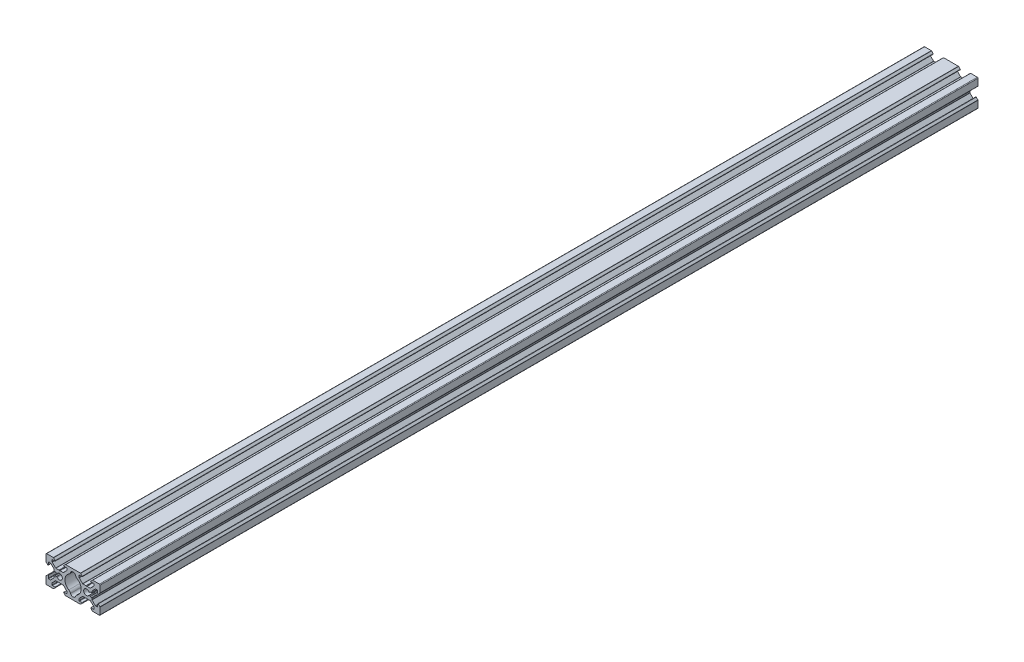
from build123d import *

# Parameters (mm, degrees)
BOSS_EXTRUDE1_DEPTH = 650


with BuildPart() as part:
    # Model → Boss-Extrude1 (new body)
    with BuildSketch(Plane.XY):
        with BuildLine():
            Line((2260.91910134, 1499.253690176), (2259.598426375, 1499.253690176))
            ThreePointArc((2259.598426375, 1499.253690176), (2259.42164968, 1499.180466871), (2259.348426375, 1499.003690176))
            Line((2259.348426375, 1499.003690176), (2259.348426375, 1497.153690176))
            ThreePointArc((2259.348426375, 1497.153690176), (2259.194097233, 1496.922720293), (2258.92164968, 1496.97691348))
            Line((2258.92164968, 1496.97691348), (2257.736294341, 1498.16226882))
            ThreePointArc((2257.736294341, 1498.16226882), (2257.671262515, 1498.259595824), (2257.648426375, 1498.374400854))
            Line((2257.648426375, 1498.374400854), (2257.648426375, 1503.303690176))
            ThreePointArc((2257.648426375, 1503.303690176), (2257.794872984, 1503.657243566), (2258.148426375, 1503.803690176))
            Line((2258.148426375, 1503.803690176), (2263.077715697, 1503.803690176))
            ThreePointArc((2263.077715697, 1503.803690176), (2263.192520727, 1503.780854036), (2263.289847731, 1503.71582221))
            Line((2263.289847731, 1503.71582221), (2264.47520307, 1502.530466871))
            ThreePointArc((2264.47520307, 1502.530466871), (2264.529396258, 1502.258019318), (2264.298426375, 1502.103690176))
            Line((2264.298426375, 1502.103690176), (2262.448426375, 1502.103690176))
            ThreePointArc((2262.448426375, 1502.103690176), (2262.27164968, 1502.030466871), (2262.198426375, 1501.853690176))
            Line((2262.198426375, 1501.853690176), (2262.198426375, 1500.533015211))
            ThreePointArc((2262.198426375, 1500.533015211), (2262.217456492, 1500.437344353), (2262.27164968, 1500.356238516))
            Line((2262.27164968, 1500.356238516), (2264.750974715, 1497.87691348))
            ThreePointArc((2264.750974715, 1497.87691348), (2264.832080552, 1497.822720293), (2264.92775141, 1497.803690176))
            Line((2264.92775141, 1497.803690176), (2267.187449152, 1497.803690176))
            ThreePointArc((2267.187449152, 1497.803690176), (2267.33046854, 1497.767404898), (2267.438891274, 1497.667326539))
            ThreePointArc((2267.438891274, 1497.667326539), (2267.648426375, 1497.553690176), (2267.857961476, 1497.667326539))
            ThreePointArc((2267.857961476, 1497.667326539), (2267.96638421, 1497.767404898), (2268.109403598, 1497.803690176))
            Line((2268.109403598, 1497.803690176), (2270.36910134, 1497.803690176))
            ThreePointArc((2270.36910134, 1497.803690176), (2270.464772198, 1497.822720293), (2270.545878035, 1497.87691348))
            Line((2270.545878035, 1497.87691348), (2273.02520307, 1500.356238516))
            ThreePointArc((2273.02520307, 1500.356238516), (2273.079396258, 1500.437344353), (2273.098426375, 1500.533015211))
            Line((2273.098426375, 1500.533015211), (2273.098426375, 1501.853690176))
            ThreePointArc((2273.098426375, 1501.853690176), (2273.02520307, 1502.030466871), (2272.848426375, 1502.103690176))
            Line((2272.848426375, 1502.103690176), (2270.998426375, 1502.103690176))
            ThreePointArc((2270.998426375, 1502.103690176), (2270.767456492, 1502.258019318), (2270.82164968, 1502.530466871))
            Line((2270.82164968, 1502.530466871), (2272.007005019, 1503.71582221))
            ThreePointArc((2272.007005019, 1503.71582221), (2272.104332024, 1503.780854036), (2272.219137053, 1503.803690176))
            Line((2272.219137053, 1503.803690176), (2283.077715697, 1503.803690176))
            ThreePointArc((2283.077715697, 1503.803690176), (2283.192520727, 1503.780854036), (2283.289847731, 1503.71582221))
            Line((2283.289847731, 1503.71582221), (2284.47520307, 1502.530466871))
            ThreePointArc((2284.47520307, 1502.530466871), (2284.529396258, 1502.258019318), (2284.298426375, 1502.103690176))
            Line((2284.298426375, 1502.103690176), (2282.448426375, 1502.103690176))
            ThreePointArc((2282.448426375, 1502.103690176), (2282.27164968, 1502.030466871), (2282.198426375, 1501.853690176))
            Line((2282.198426375, 1501.853690176), (2282.198426375, 1500.533015211))
            ThreePointArc((2282.198426375, 1500.533015211), (2282.217456492, 1500.437344353), (2282.27164968, 1500.356238516))
            Line((2282.27164968, 1500.356238516), (2284.750974715, 1497.87691348))
            ThreePointArc((2284.750974715, 1497.87691348), (2284.832080552, 1497.822720293), (2284.92775141, 1497.803690176))
            Line((2284.92775141, 1497.803690176), (2287.187449152, 1497.803690176))
            ThreePointArc((2287.187449152, 1497.803690176), (2287.33046854, 1497.767404898), (2287.438891274, 1497.667326539))
            ThreePointArc((2287.438891274, 1497.667326539), (2287.648426375, 1497.553690176), (2287.857961476, 1497.667326539))
            ThreePointArc((2287.857961476, 1497.667326539), (2287.96638421, 1497.767404898), (2288.109403598, 1497.803690176))
            Line((2288.109403598, 1497.803690176), (2290.36910134, 1497.803690176))
            ThreePointArc((2290.36910134, 1497.803690176), (2290.464772198, 1497.822720293), (2290.545878035, 1497.87691348))
            Line((2290.545878035, 1497.87691348), (2293.02520307, 1500.356238516))
            ThreePointArc((2293.02520307, 1500.356238516), (2293.079396258, 1500.437344353), (2293.098426375, 1500.533015211))
            Line((2293.098426375, 1500.533015211), (2293.098426375, 1501.853690176))
            ThreePointArc((2293.098426375, 1501.853690176), (2293.02520307, 1502.030466871), (2292.848426375, 1502.103690176))
            Line((2292.848426375, 1502.103690176), (2290.998426375, 1502.103690176))
            ThreePointArc((2290.998426375, 1502.103690176), (2290.767456492, 1502.258019318), (2290.82164968, 1502.530466871))
            Line((2290.82164968, 1502.530466871), (2292.007005019, 1503.71582221))
            ThreePointArc((2292.007005019, 1503.71582221), (2292.104332023, 1503.780854036), (2292.219137053, 1503.803690176))
            Line((2292.219137053, 1503.803690176), (2297.148426375, 1503.803690176))
            ThreePointArc((2297.148426375, 1503.803690176), (2297.501979766, 1503.657243566), (2297.648426375, 1503.303690176))
            Line((2297.648426375, 1503.303690176), (2297.648426375, 1498.374400854))
            ThreePointArc((2297.648426375, 1498.374400854), (2297.625590235, 1498.259595824), (2297.560558409, 1498.16226882))
            Line((2297.560558409, 1498.16226882), (2296.37520307, 1496.97691348))
            ThreePointArc((2296.37520307, 1496.97691348), (2296.102755517, 1496.922720293), (2295.948426375, 1497.153690176))
            Line((2295.948426375, 1497.153690176), (2295.948426375, 1499.003690176))
            ThreePointArc((2295.948426375, 1499.003690176), (2295.87520307, 1499.180466871), (2295.698426375, 1499.253690176))
            Line((2295.698426375, 1499.253690176), (2294.37775141, 1499.253690176))
            ThreePointArc((2294.37775141, 1499.253690176), (2294.282080552, 1499.234660059), (2294.200974715, 1499.180466871))
            Line((2294.200974715, 1499.180466871), (2291.736294341, 1496.715786497))
            ThreePointArc((2291.736294341, 1496.715786497), (2291.671262515, 1496.618459492), (2291.648426375, 1496.503654462))
            Line((2291.648426375, 1496.503654462), (2291.648426375, 1495.603690176))
            ThreePointArc((2291.648426375, 1495.603690176), (2291.560558409, 1495.391558141), (2291.348426375, 1495.303690176))
            Line((2291.348426375, 1495.303690176), (2290.448462088, 1495.303690176))
            ThreePointArc((2290.448462088, 1495.303690176), (2290.333657059, 1495.280854035), (2290.236330054, 1495.21582221))
            Line((2290.236330054, 1495.21582221), (2289.891246967, 1494.870739123))
            ThreePointArc((2289.891246967, 1494.870739123), (2289.645694653, 1494.784738494), (2289.425278863, 1494.922973534))
            ThreePointArc((2289.425278863, 1494.922973534), (2285.548426375, 1493.803690176), (2289.425278863, 1492.684406817))
            ThreePointArc((2289.425278863, 1492.684406817), (2289.645694653, 1492.822641858), (2289.891246967, 1492.736641229))
            Line((2289.891246967, 1492.736641229), (2290.236330054, 1492.391558141))
            ThreePointArc((2290.236330054, 1492.391558141), (2290.333657059, 1492.326526316), (2290.448462089, 1492.303690176))
            Line((2290.448462089, 1492.303690176), (2291.348426375, 1492.303690176))
            ThreePointArc((2291.348426375, 1492.303690176), (2291.560558409, 1492.21582221), (2291.648426375, 1492.003690176))
            Line((2291.648426375, 1492.003690176), (2291.648426375, 1491.103725889))
            ThreePointArc((2291.648426375, 1491.103725889), (2291.671262515, 1490.988920859), (2291.736294341, 1490.891593855))
            Line((2291.736294341, 1490.891593855), (2294.200974715, 1488.42691348))
            ThreePointArc((2294.200974715, 1488.42691348), (2294.282080552, 1488.372720293), (2294.37775141, 1488.353690176))
            Line((2294.37775141, 1488.353690176), (2295.698426375, 1488.353690176))
            ThreePointArc((2295.698426375, 1488.353690176), (2295.87520307, 1488.42691348), (2295.948426375, 1488.603690176))
            Line((2295.948426375, 1488.603690176), (2295.948426375, 1490.453690176))
            ThreePointArc((2295.948426375, 1490.453690176), (2296.102755517, 1490.684660059), (2296.37520307, 1490.630466871))
            Line((2296.37520307, 1490.630466871), (2297.560558409, 1489.445111532))
            ThreePointArc((2297.560558409, 1489.445111532), (2297.625590235, 1489.347784527), (2297.648426375, 1489.232979498))
            Line((2297.648426375, 1489.232979498), (2297.648426375, 1484.303690176))
            ThreePointArc((2297.648426375, 1484.303690176), (2297.501979766, 1483.950136785), (2297.148426375, 1483.803690176))
            Line((2297.148426375, 1483.803690176), (2292.219137053, 1483.803690176))
            ThreePointArc((2292.219137053, 1483.803690176), (2292.104332023, 1483.826526316), (2292.007005019, 1483.891558141))
            Line((2292.007005019, 1483.891558141), (2290.82164968, 1485.07691348))
            ThreePointArc((2290.82164968, 1485.07691348), (2290.767456492, 1485.349361034), (2290.998426375, 1485.503690176))
            Line((2290.998426375, 1485.503690176), (2292.848426375, 1485.503690176))
            ThreePointArc((2292.848426375, 1485.503690176), (2293.02520307, 1485.57691348), (2293.098426375, 1485.753690176))
            Line((2293.098426375, 1485.753690176), (2293.098426375, 1487.07436514))
            ThreePointArc((2293.098426375, 1487.07436514), (2293.079396258, 1487.170035999), (2293.02520307, 1487.251141836))
            Line((2293.02520307, 1487.251141836), (2290.545878035, 1489.730466871))
            ThreePointArc((2290.545878035, 1489.730466871), (2290.464772198, 1489.784660059), (2290.36910134, 1489.803690176))
            Line((2290.36910134, 1489.803690176), (2288.109403598, 1489.803690176))
            ThreePointArc((2288.109403598, 1489.803690176), (2287.96638421, 1489.839975454), (2287.857961477, 1489.940053812))
            ThreePointArc((2287.857961477, 1489.940053812), (2287.648426375, 1490.053690176), (2287.438891274, 1489.940053812))
            ThreePointArc((2287.438891274, 1489.940053812), (2287.33046854, 1489.839975454), (2287.187449152, 1489.803690176))
            Line((2287.187449152, 1489.803690176), (2284.92775141, 1489.803690176))
            ThreePointArc((2284.92775141, 1489.803690176), (2284.832080552, 1489.784660059), (2284.750974715, 1489.730466871))
            Line((2284.750974715, 1489.730466871), (2282.27164968, 1487.251141836))
            ThreePointArc((2282.27164968, 1487.251141836), (2282.217456492, 1487.170035999), (2282.198426375, 1487.07436514))
            Line((2282.198426375, 1487.07436514), (2282.198426375, 1485.753690176))
            ThreePointArc((2282.198426375, 1485.753690176), (2282.27164968, 1485.57691348), (2282.448426375, 1485.503690176))
            Line((2282.448426375, 1485.503690176), (2284.298426375, 1485.503690176))
            ThreePointArc((2284.298426375, 1485.503690176), (2284.529396258, 1485.349361034), (2284.47520307, 1485.07691348))
            Line((2284.47520307, 1485.07691348), (2283.289847731, 1483.891558141))
            ThreePointArc((2283.289847731, 1483.891558141), (2283.192520727, 1483.826526316), (2283.077715697, 1483.803690176))
            Line((2283.077715697, 1483.803690176), (2272.219137053, 1483.803690176))
            ThreePointArc((2272.219137053, 1483.803690176), (2272.104332024, 1483.826526316), (2272.007005019, 1483.891558141))
            Line((2272.007005019, 1483.891558141), (2270.82164968, 1485.07691348))
            ThreePointArc((2270.82164968, 1485.07691348), (2270.767456492, 1485.349361034), (2270.998426375, 1485.503690176))
            Line((2270.998426375, 1485.503690176), (2272.848426375, 1485.503690176))
            ThreePointArc((2272.848426375, 1485.503690176), (2273.02520307, 1485.57691348), (2273.098426375, 1485.753690176))
            Line((2273.098426375, 1485.753690176), (2273.098426375, 1487.07436514))
            ThreePointArc((2273.098426375, 1487.07436514), (2273.079396258, 1487.170035999), (2273.02520307, 1487.251141836))
            Line((2273.02520307, 1487.251141836), (2270.545878035, 1489.730466871))
            ThreePointArc((2270.545878035, 1489.730466871), (2270.464772198, 1489.784660059), (2270.36910134, 1489.803690176))
            Line((2270.36910134, 1489.803690176), (2268.109403598, 1489.803690176))
            ThreePointArc((2268.109403598, 1489.803690176), (2267.96638421, 1489.839975454), (2267.857961476, 1489.940053812))
            ThreePointArc((2267.857961476, 1489.940053812), (2267.648426375, 1490.053690176), (2267.438891274, 1489.940053812))
            ThreePointArc((2267.438891274, 1489.940053812), (2267.33046854, 1489.839975454), (2267.187449152, 1489.803690176))
            Line((2267.187449152, 1489.803690176), (2264.92775141, 1489.803690176))
            ThreePointArc((2264.92775141, 1489.803690176), (2264.832080552, 1489.784660059), (2264.750974715, 1489.730466871))
            Line((2264.750974715, 1489.730466871), (2262.27164968, 1487.251141836))
            ThreePointArc((2262.27164968, 1487.251141836), (2262.217456492, 1487.170035999), (2262.198426375, 1487.074365141))
            Line((2262.198426375, 1487.074365141), (2262.198426375, 1485.753690176))
            ThreePointArc((2262.198426375, 1485.753690176), (2262.27164968, 1485.57691348), (2262.448426375, 1485.503690176))
            Line((2262.448426375, 1485.503690176), (2264.298426375, 1485.503690176))
            ThreePointArc((2264.298426375, 1485.503690176), (2264.529396258, 1485.349361034), (2264.47520307, 1485.07691348))
            Line((2264.47520307, 1485.07691348), (2263.289847731, 1483.891558141))
            ThreePointArc((2263.289847731, 1483.891558141), (2263.192520727, 1483.826526316), (2263.077715697, 1483.803690176))
            Line((2263.077715697, 1483.803690176), (2258.148426375, 1483.803690176))
            ThreePointArc((2258.148426375, 1483.803690176), (2257.794872984, 1483.950136785), (2257.648426375, 1484.303690176))
            Line((2257.648426375, 1484.303690176), (2257.648426375, 1489.232979498))
            ThreePointArc((2257.648426375, 1489.232979498), (2257.671262515, 1489.347784527), (2257.736294341, 1489.445111532))
            Line((2257.736294341, 1489.445111532), (2258.92164968, 1490.630466871))
            ThreePointArc((2258.92164968, 1490.630466871), (2259.194097233, 1490.684660059), (2259.348426375, 1490.453690176))
            Line((2259.348426375, 1490.453690176), (2259.348426375, 1488.603690176))
            ThreePointArc((2259.348426375, 1488.603690176), (2259.42164968, 1488.42691348), (2259.598426375, 1488.353690176))
            Line((2259.598426375, 1488.353690176), (2260.91910134, 1488.353690176))
            ThreePointArc((2260.91910134, 1488.353690176), (2261.014772198, 1488.372720293), (2261.095878035, 1488.42691348))
            Line((2261.095878035, 1488.42691348), (2263.560558409, 1490.891593855))
            ThreePointArc((2263.560558409, 1490.891593855), (2263.625590235, 1490.988920859), (2263.648426375, 1491.103725889))
            Line((2263.648426375, 1491.103725889), (2263.648426375, 1492.003690176))
            ThreePointArc((2263.648426375, 1492.003690176), (2263.736294341, 1492.21582221), (2263.948426375, 1492.303690176))
            Line((2263.948426375, 1492.303690176), (2264.848390662, 1492.303690176))
            ThreePointArc((2264.848390662, 1492.303690176), (2264.963195691, 1492.326526316), (2265.060522696, 1492.391558141))
            Line((2265.060522696, 1492.391558141), (2265.405605783, 1492.736641229))
            ThreePointArc((2265.405605783, 1492.736641229), (2265.651158097, 1492.822641858), (2265.871573887, 1492.684406817))
            ThreePointArc((2265.871573887, 1492.684406817), (2269.748426375, 1493.803690176), (2265.871573887, 1494.922973534))
            ThreePointArc((2265.871573887, 1494.922973534), (2265.651158097, 1494.784738494), (2265.405605783, 1494.870739123))
            Line((2265.405605783, 1494.870739123), (2265.060522696, 1495.21582221))
            ThreePointArc((2265.060522696, 1495.21582221), (2264.963195691, 1495.280854035), (2264.848390662, 1495.303690176))
            Line((2264.848390662, 1495.303690176), (2263.948426375, 1495.303690176))
            ThreePointArc((2263.948426375, 1495.303690176), (2263.736294341, 1495.391558141), (2263.648426375, 1495.603690176))
            Line((2263.648426375, 1495.603690176), (2263.648426375, 1496.503654462))
            ThreePointArc((2263.648426375, 1496.503654462), (2263.625590235, 1496.618459492), (2263.560558409, 1496.715786497))
            Line((2263.560558409, 1496.715786497), (2261.095878035, 1499.180466871))
            ThreePointArc((2261.095878035, 1499.180466871), (2261.014772198, 1499.234660059), (2260.91910134, 1499.253690176))
        make_face()
        with BuildLine():
            ThreePointArc((2275.774334674, 1487.105277477), (2275.24913328, 1488.022454297), (2274.457405371, 1488.722609095))
            ThreePointArc((2274.457405371, 1488.722609095), (2271.648426375, 1493.803690176), (2274.457405371, 1498.884771257))
            ThreePointArc((2274.457405371, 1498.884771257), (2275.24913328, 1499.584926055), (2275.774334674, 1500.502102874))
            ThreePointArc((2275.774334674, 1500.502102874), (2277.648426375, 1501.803690176), (2279.522518076, 1500.502102874))
            ThreePointArc((2279.522518076, 1500.502102874), (2280.04771947, 1499.584926055), (2280.839447379, 1498.884771257))
            ThreePointArc((2280.839447379, 1498.884771257), (2283.648426375, 1493.803690176), (2280.839447379, 1488.722609095))
            ThreePointArc((2280.839447379, 1488.722609095), (2280.04771947, 1488.022454297), (2279.522518076, 1487.105277477))
            ThreePointArc((2279.522518076, 1487.105277477), (2277.648426375, 1485.803690176), (2275.774334674, 1487.105277477))
        make_face(mode=Mode.SUBTRACT)
    extrude(amount=BOSS_EXTRUDE1_DEPTH)


solid = part.part
